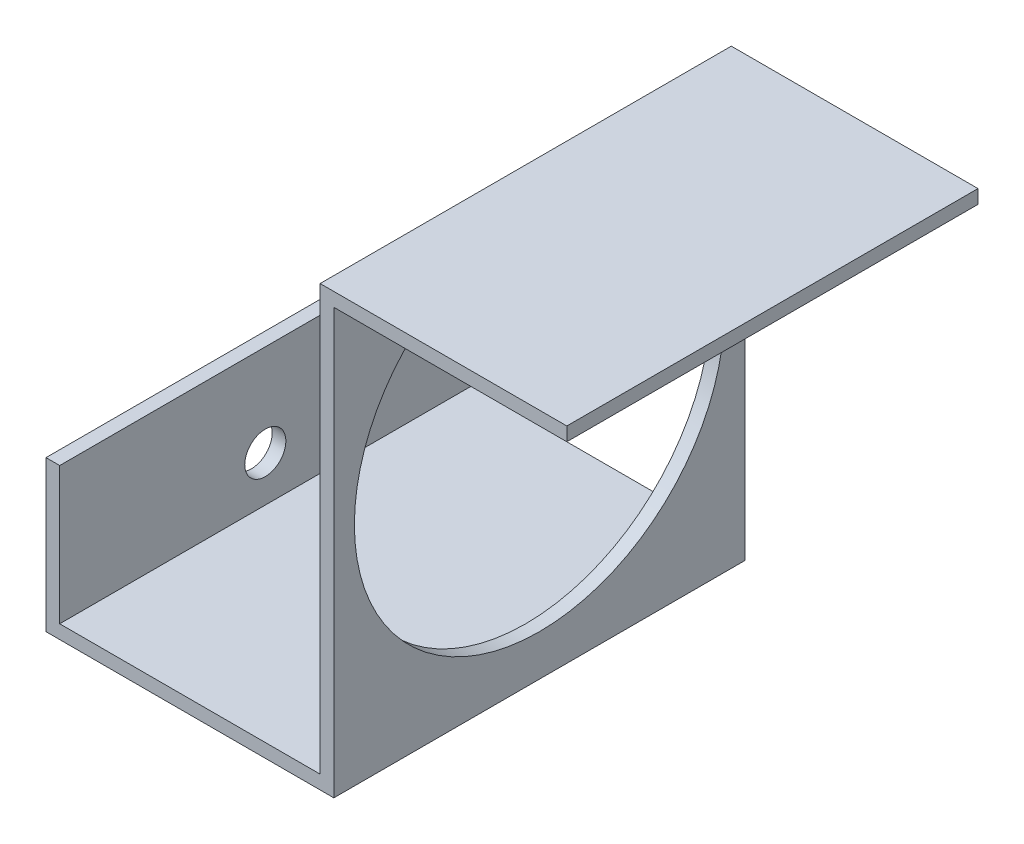
from build123d import *

# Parameters (mm, degrees)
EXTRUDE_1_DEPTH     = 30
SKETCH_4_R          = 1.5
CUT_EXTRUDE_3_DEPTH = 2
SKETCH_5_R          = 13.5
CUT_EXTRUDE_4_DEPTH = 5


with BuildPart() as part:
    # 草图1 → 凸台-拉伸1 (new body)
    with BuildSketch(Plane.XY):
        Polygon((-21.167340442, 37.672826145), (-21.167340442, 27.672826145), (-2.167340442, 27.672826145), (-2.167340442, 58.672826145), (15.832659558, 58.672826145), (15.832659558, 57.672826145), (-1.167340442, 57.672826145), (-1.167340442, 26.672826145), (-22.167340442, 26.672826145), (-22.167340442, 37.672826145), align=None)
    extrude(amount=EXTRUDE_1_DEPTH)

    # 草图4 → 切除-拉伸3 (cut)
    with BuildSketch(Plane.ZY.offset(22.167340442)):
        with Locations((15, 30.972826145)):
            Circle(SKETCH_4_R)
    extrude(amount=-CUT_EXTRUDE_3_DEPTH, mode=Mode.SUBTRACT)

    # 草图5 → 切除-拉伸4 (cut)
    with BuildSketch(Plane.ZY.offset(2.167340442)):
        with Locations((15, 43.172826145)):
            Circle(SKETCH_5_R)
    extrude(amount=-CUT_EXTRUDE_4_DEPTH, mode=Mode.SUBTRACT)


solid = part.part
